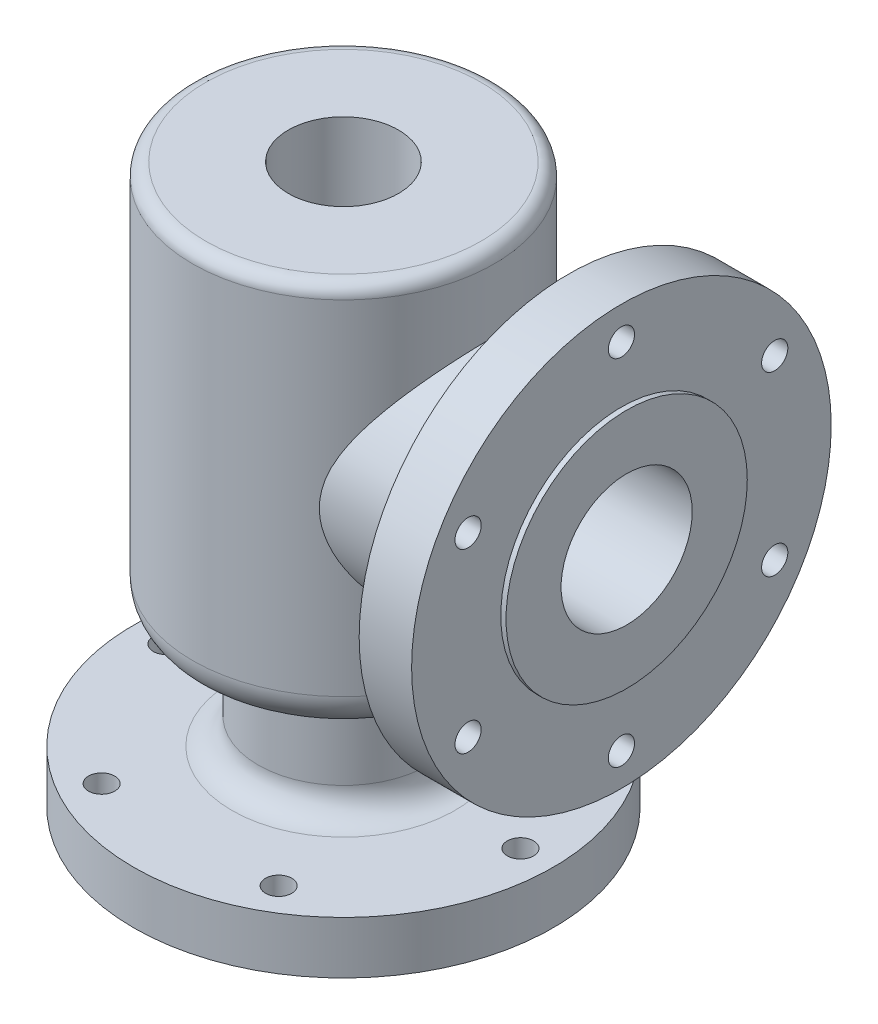
from build123d import *

# Parameters (mm, degrees)
ZAOBLIT1_R               = 10
ZAOBLIT2_R               = 14
ZKOSEN_1_SIZE            = 8
ZAOBLIT3_R               = 5
SKICA3_R                 = 5
ODEBRAT_VYSUNUT_M3_DEPTH = 20
KRUHOV_POLE1_COUNT       = 6
P_IDAT_VYSUNUT_M2_REACH  = 168
SKICA4_R                 = 45
SKICA5_R                 = 80
P_IDAT_VYSUNUT_M3_DEPTH  = 20
SKICA6_R                 = 46
P_IDAT_VYSUNUT_M4_DEPTH  = 2
ODEBRAT_VYSUNUT_M4_REACH = 190
SKICA7_R                 = 25
SKICA8_R                 = 5
ODEBRAT_VYSUNUT_M5_DEPTH = 20
KRUHOV_POLE2_COUNT       = 6


with BuildPart() as part:
    # Skica1 → Rotovat1 (revolve)
    with BuildSketch(Plane.XY):
        Polygon((57.5, 0), (21, 0), (21, -30), (43, -30), (43, -118), (12.5, -118), (12.5, -215), (45, -215), (45, -213), (80, -213), (80, -193), (32.5, -193), (32.5, -150), (57.5, -150), align=None)
    revolve(axis=Axis((0, 44.732136913, 0), (0, -1, 0)))

    # Zaoblit1
    zaoblit1_edges = [part.edges().sort_by_distance(p)[0] for p in [
        (-43, -118, 0),
        (-43, -30, 0),
        (-32.5, -150, 0),
        (-32.5, -193, 0),
    ]]
    fillet(zaoblit1_edges, radius=ZAOBLIT1_R)

    # Zaoblit2
    zaoblit2_edges = [part.edges().sort_by_distance(p)[0] for p in [
        (-57.5, -150, 0),
    ]]
    fillet(zaoblit2_edges, radius=ZAOBLIT2_R)

    # Zkosení1
    zkosen_1_edges = [part.edges().sort_by_distance(p)[0] for p in [
        (-12.5, -118, 0),
    ]]
    chamfer(zkosen_1_edges, length=ZKOSEN_1_SIZE)

    # Zaoblit3
    zaoblit3_edges = [part.edges().sort_by_distance(p)[0] for p in [
        (-57.5, 0, 0),
    ]]
    fillet(zaoblit3_edges, radius=ZAOBLIT3_R)

    # Skica3 → Odebrat vysunutím3 (cut)
    with BuildSketch(Plane.XZ.offset(213)):
        with Locations((67.5, 0)):
            Circle(SKICA3_R)
    odebrat_vysunut_m3 = extrude(amount=-ODEBRAT_VYSUNUT_M3_DEPTH, mode=Mode.SUBTRACT)

    # Kruhové pole1: Odebrat vysunutím3 ×6 about axis
    kruhov_pole1_axis = Axis((0, 0, 0), (0, 1, 0))
    for i in range(1, KRUHOV_POLE1_COUNT):
        add(odebrat_vysunut_m3.rotate(kruhov_pole1_axis, i * 360 / KRUHOV_POLE1_COUNT), mode=Mode.SUBTRACT)

    # Skica4 → Přidat vysunutím2 (add, up to next)
    with BuildSketch(Plane(origin=(86, 0, 0), x_dir=(0, 0, -1), z_dir=(1, 0, 0)), mode=Mode.PRIVATE) as p_idat_vysunut_m2_sk1:
        with Locations((0, -74)):
            Circle(SKICA4_R)
    p_idat_vysunut_m2_tool1 = extrude(p_idat_vysunut_m2_sk1.sketch, amount=-P_IDAT_VYSUNUT_M2_REACH, mode=Mode.PRIVATE) - part.part
    add(p_idat_vysunut_m2_tool1.solids().sort_by_distance((86, -74, 0))[0])

    # Skica5 → Přidat vysunutím3 (add)
    with BuildSketch(Plane(origin=(86, 0, 0), x_dir=(0, 0, -1), z_dir=(1, 0, 0))):
        with Locations((0, -74)):
            Circle(SKICA5_R)
    extrude(amount=P_IDAT_VYSUNUT_M3_DEPTH)

    # Skica6 → Přidat vysunutím4 (add)
    with BuildSketch(Plane(origin=(106, 0, 0), x_dir=(0, 0, -1), z_dir=(1, 0, 0))):
        with Locations((0, -74)):
            Circle(SKICA6_R)
    extrude(amount=P_IDAT_VYSUNUT_M4_DEPTH)

    # Skica7 → Odebrat vysunutím4 (cut, up to next)
    with BuildSketch(Plane(origin=(108, 0, 0), x_dir=(0, 0, -1), z_dir=(1, 0, 0)), mode=Mode.PRIVATE) as odebrat_vysunut_m4_sk1:
        with Locations((0, -74)):
            Circle(SKICA7_R)
    odebrat_vysunut_m4_tool1 = extrude(odebrat_vysunut_m4_sk1.sketch, amount=-ODEBRAT_VYSUNUT_M4_REACH, mode=Mode.PRIVATE) & part.part
    add(odebrat_vysunut_m4_tool1.solids().sort_by_distance((108, -74, 0))[0], mode=Mode.SUBTRACT)

    # Skica8 → Odebrat vysunutím5 (cut)
    with BuildSketch(Plane(origin=(106, 0, 0), x_dir=(0, 0, -1), z_dir=(1, 0, 0))):
        with Locations((0, -6.5)):
            Circle(SKICA8_R)
    odebrat_vysunut_m5 = extrude(amount=-ODEBRAT_VYSUNUT_M5_DEPTH, mode=Mode.SUBTRACT)

    # Kruhové pole2: Odebrat vysunutím5 ×6 about axis
    kruhov_pole2_axis = Axis((0, -74, 0), (1, 0, 0))
    for i in range(1, KRUHOV_POLE2_COUNT):
        add(odebrat_vysunut_m5.rotate(kruhov_pole2_axis, i * 360 / KRUHOV_POLE2_COUNT), mode=Mode.SUBTRACT)


solid = part.part
